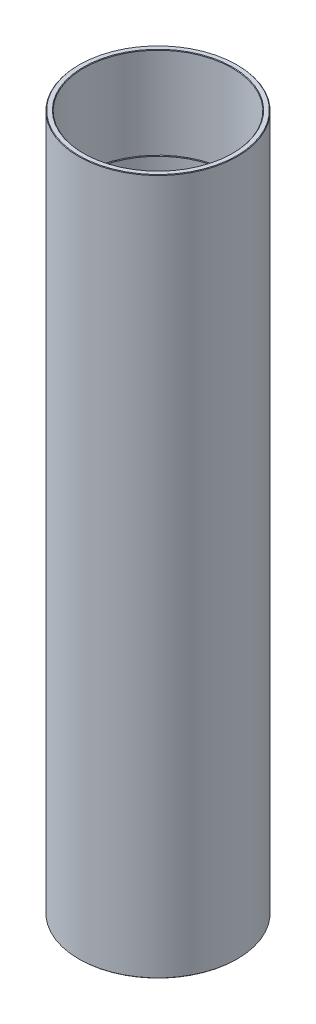
from build123d import *

# Parameters (mm, degrees)
CHAMFER_1_SIZE = 0.2
CHAMFER_2_SIZE = 0.2
CHAMFER_3_SIZE = 0.2
CHAMFER_4_SIZE = 0.2


with BuildPart() as part:
    # Эскиз1 → Повернуть1 (revolve)
    with BuildSketch(Plane.XY):
        Polygon((-30.2, 0), (-30.2, 264.999961118), (-28.25, 264.999961118), (-28.25, 229.999961118), (-28, 229.999961118), (-28, 25), (-28.25, 25), (-28.25, 0), align=None)
    revolve(axis=Axis((0, 0, 0), (0, 1, 0)))

    # Фаска1
    chamfer_1_edges = [part.edges().sort_by_distance(p)[0] for p in [
        (30.2, 264.999961118, 0),
    ]]
    chamfer(chamfer_1_edges, length=CHAMFER_1_SIZE)

    # Фаска2
    chamfer_2_edges = [part.edges().sort_by_distance(p)[0] for p in [
        (28.25, 264.999961118, 0),
        (28.25, 229.999961118, 0),
    ]]
    chamfer(chamfer_2_edges, length=CHAMFER_2_SIZE)

    # Фаска3
    chamfer_3_edges = [part.edges().sort_by_distance(p)[0] for p in [
        (30.2, 0, 0),
    ]]
    chamfer(chamfer_3_edges, length=CHAMFER_3_SIZE)

    # Фаска4
    chamfer_4_edges = [part.edges().sort_by_distance(p)[0] for p in [
        (28.25, 0, 0),
    ]]
    chamfer(chamfer_4_edges, length=CHAMFER_4_SIZE)


solid = part.part
